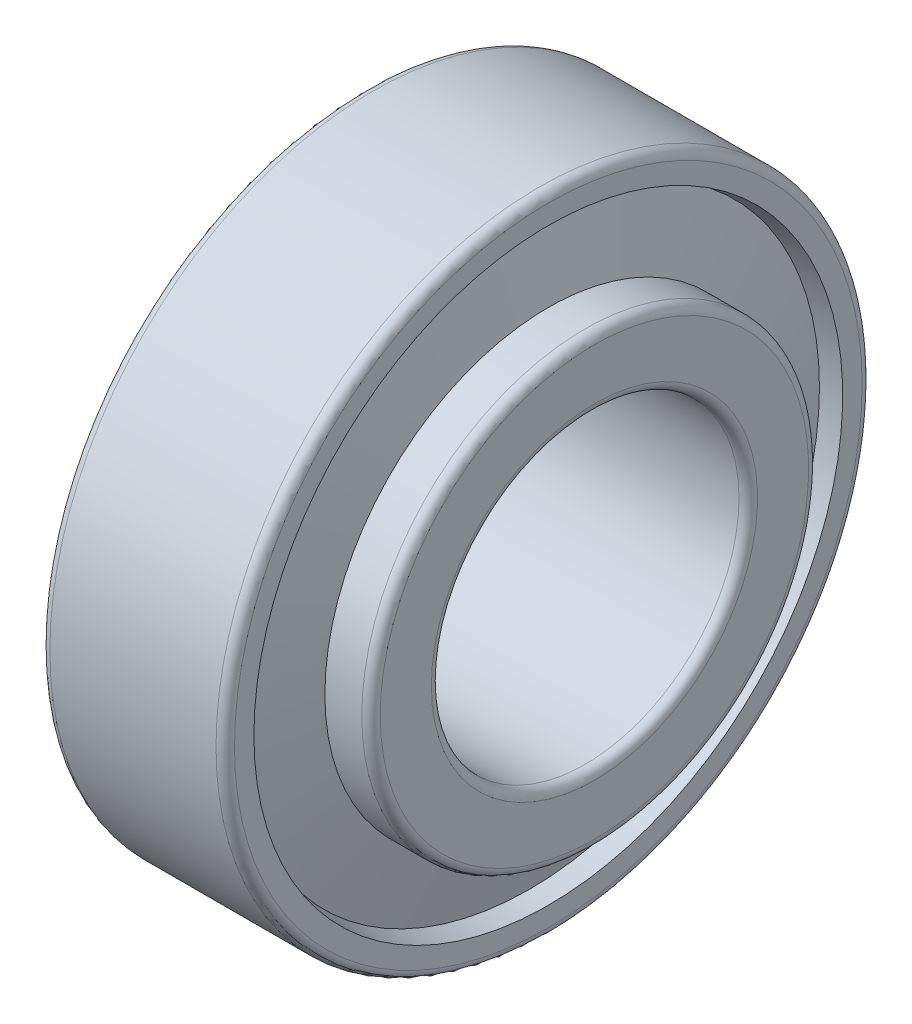
from build123d import *


with BuildPart() as part:
    # Эскиз1 → Повернуть1 (revolve)
    with BuildSketch(Plane.XY):
        with BuildLine():
            Line((1.320047805, 16.692775518), (0, 16.3905))
            Line((0, 16.3905), (0, 20.4))
            ThreePointArc((0, 20.4), (0.175735931, 20.824264069), (0.6, 21))
            Line((0.6, 21), (11.4, 21))
            ThreePointArc((11.4, 21), (11.824264069, 20.824264069), (12, 20.4))
            Line((12, 20.4), (12, 19.138359743))
            Line((12, 19.138359743), (10.770190726, 18.856747793))
            Line((10.770190726, 18.856747793), (12, 13.924252207))
            Line((12, 13.924252207), (12, 14.524252207))
            Line((12, 14.524252207), (14.4, 14.524252207))
            ThreePointArc((14.4, 14.524252207), (14.824264069, 14.348516276), (15, 13.924252207))
            Line((15, 13.924252207), (15, 10.6))
            ThreePointArc((15, 10.6), (14.824264069, 10.175735931), (14.4, 10))
            Line((14.4, 10), (0.6, 10))
            ThreePointArc((0.6, 10), (0.175735931, 10.175735931), (0, 10.6))
            Line((0, 10.6), (0, 11.398352952))
            Line((0, 11.398352952), (2.640095609, 11.398352952))
            Line((2.640095609, 11.398352952), (1.320047805, 16.692775518))
        make_face()
    revolve(axis=Axis((-882.527700014, 0, 0), (1, 0, 0)))


solid = part.part
